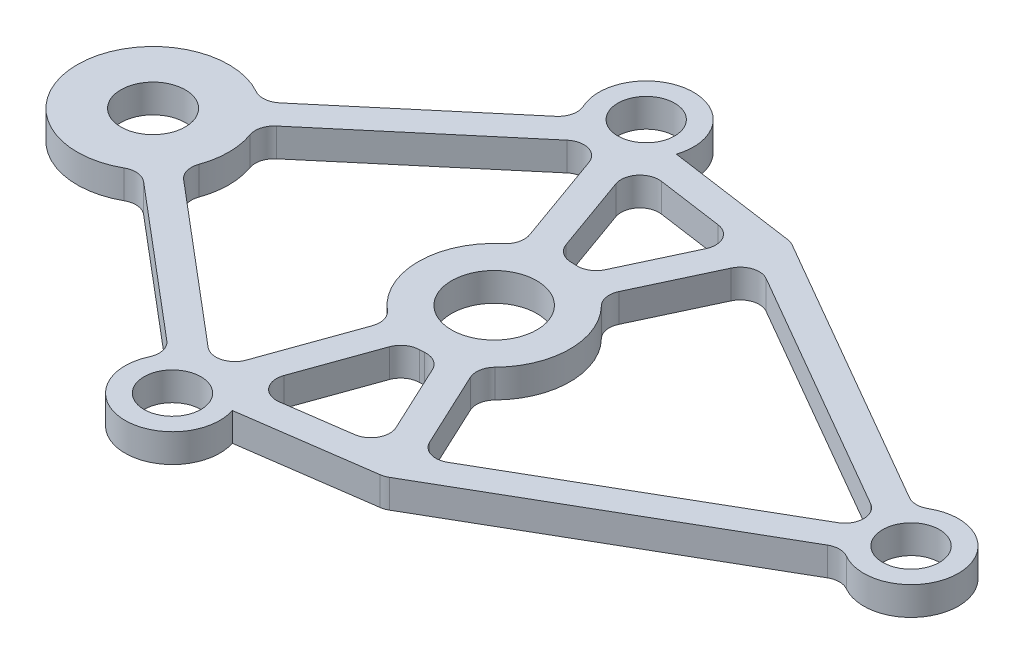
from build123d import *

# Parameters (mm, degrees)
SKETCH_1_R      = 2.25
SKETCH_1_R_2    = 1.7
SKETCH_1_R_3    = 1.5
EXTRUDE_1_DEPTH = 1.5


with BuildPart() as part:
    # 草图1 → 凸台-拉伸1 (new body)
    with BuildSketch(Plane(origin=(0, 0, 0), x_dir=(1, 0, 0), z_dir=(0, 1, 0))):
        with BuildLine():
            Line((19.75, 2.165063509), (5.096488448, 10.625272348))
            ThreePointArc((5.096488448, 10.625272348), (4.922427124, 10.704637858), (4.736437674, 10.749405626))
            Line((4.736437674, 10.749405626), (-2.101908222, 11.7159388))
            ThreePointArc((-2.101908222, 11.7159388), (-4.61878361, 14.995906411), (-6.744553684, 11.449929699))
            ThreePointArc((-6.744553684, 11.449929699), (-6.675732942, 10.813623622), (-7.006838923, 10.265909693))
            Line((-7.006838923, 10.265909693), (-14.905573539, 3.595069524))
            ThreePointArc((-14.905573539, 3.595069524), (-15.456234647, 3.363542696), (-16.040639512, 3.487249128))
            ThreePointArc((-16.040639512, 3.487249128), (-22, 0), (-16.040639512, -3.487249128))
            ThreePointArc((-16.040639512, -3.487249128), (-15.456234647, -3.363542696), (-14.905573539, -3.595069524))
            Line((-14.905573539, -3.595069524), (-7.006838923, -10.265909693))
            ThreePointArc((-7.006838923, -10.265909693), (-6.675732942, -10.813623622), (-6.744553684, -11.449929699))
            ThreePointArc((-6.744553684, -11.449929699), (-4.61878361, -14.995906411), (-2.101908222, -11.7159388))
            Line((-2.101908222, -11.7159388), (4.736437674, -10.749405626))
            ThreePointArc((4.736437674, -10.749405626), (4.922427124, -10.704637858), (5.096488448, -10.625272348))
            Line((5.096488448, -10.625272348), (19.75, -2.165063509))
            ThreePointArc((19.75, -2.165063509), (20.25, -2.031088913), (20.75, -2.165063509))
            ThreePointArc((20.75, -2.165063509), (24.5, 0), (20.75, 2.165063509))
            ThreePointArc((20.75, 2.165063509), (20.25, 2.031088913), (19.75, 2.165063509))
        make_face()
        Circle(SKETCH_1_R, mode=Mode.SUBTRACT)
        with Locations((-18, 0)):
            Circle(SKETCH_1_R_2, mode=Mode.SUBTRACT)
        with Locations((22, 0)):
            Circle(SKETCH_1_R_3, mode=Mode.SUBTRACT)
        with Locations((-4.47577596, 12.5)):
            Circle(SKETCH_1_R_3, mode=Mode.SUBTRACT)
        with Locations((-4.47577596, -12.5)):
            Circle(SKETCH_1_R_3, mode=Mode.SUBTRACT)
        with BuildLine():
            Line((2.23143448, 9.588554578), (-1.256530939, 10.081544307))
            ThreePointArc((-1.256530939, 10.081544307), (-2.171731289, 9.72303877), (-2.33794765, 8.754281823))
            Line((-2.33794765, 8.754281823), (-0.872808817, 4.662424773))
            ThreePointArc((-0.872808817, 4.662424773), (-0.512657064, 4.185850496), (0.054926934, 3.999622861))
            ThreePointArc((0.054926934, 3.999622861), (0.187612888, 3.995597753), (0.320092213, 3.987172052))
            ThreePointArc((0.320092213, 3.987172052), (0.902629068, 4.119395878), (1.305852753, 4.56012594))
            Line((1.305852753, 4.56012594), (2.997222742, 8.174556771))
            ThreePointArc((2.997222742, 8.174556771), (2.970810351, 9.074617878), (2.23143448, 9.588554578))
        make_face(mode=Mode.SUBTRACT)
        with BuildLine():
            Line((19, 0.866025404), (5.956182941, 8.396876694))
            ThreePointArc((5.956182941, 8.396876694), (5.156119776, 8.484770625), (4.550445454, 7.954690416))
            Line((4.550445454, 7.954690416), (2.664458984, 3.924367251))
            ThreePointArc((2.664458984, 3.924367251), (2.584431714, 3.332397688), (2.856157177, 2.800422501))
            ThreePointArc((2.856157177, 2.800422501), (4, 0), (2.856157177, -2.800422501))
            ThreePointArc((2.856157177, -2.800422501), (2.584431714, -3.332397688), (2.664458984, -3.924367251))
            Line((2.664458984, -3.924367251), (4.550445454, -7.954690416))
            ThreePointArc((4.550445454, -7.954690416), (5.156119776, -8.484770625), (5.956182941, -8.396876694))
            Line((5.956182941, -8.396876694), (19, -0.866025404))
            ThreePointArc((19, -0.866025404), (19.5, 0), (19, 0.866025404))
        make_face(mode=Mode.SUBTRACT)
        with BuildLine():
            Line((-2.33794765, -8.754281823), (-0.872808817, -4.662424773))
            ThreePointArc((-0.872808817, -4.662424773), (-0.512657064, -4.185850496), (0.054926934, -3.999622861))
            ThreePointArc((0.054926934, -3.999622861), (0.187612888, -3.995597753), (0.320092213, -3.987172052))
            ThreePointArc((0.320092213, -3.987172052), (0.902629068, -4.119395878), (1.305852753, -4.56012594))
            Line((1.305852753, -4.56012594), (2.997222742, -8.174556771))
            ThreePointArc((2.997222742, -8.174556771), (2.970810351, -9.074617878), (2.23143448, -9.588554578))
            Line((2.23143448, -9.588554578), (-1.256530939, -10.081544307))
            ThreePointArc((-1.256530939, -10.081544307), (-2.171731289, -9.72303877), (-2.33794765, -8.754281823))
        make_face(mode=Mode.SUBTRACT)
        with BuildLine():
            Line((-5.622052564, 9.472053038), (-13.937734763, 2.449081695))
            ThreePointArc((-13.937734763, 2.449081695), (-14.258158429, 1.944937864), (-14.23400713, 1.348071847))
            ThreePointArc((-14.23400713, 1.348071847), (-14, 0), (-14.23400713, -1.348071847))
            ThreePointArc((-14.23400713, -1.348071847), (-14.258158429, -1.944937864), (-13.937734763, -2.449081695))
            Line((-13.937734763, -2.449081695), (-5.622052564, -9.472053038))
            ThreePointArc((-5.622052564, -9.472053038), (-4.717022681, -9.673722513), (-4.035359228, -9.045164955))
            Line((-4.035359228, -9.045164955), (-2.285010045, -4.156769069))
            ThreePointArc((-2.285010045, -4.156769069), (-2.260804326, -3.559905256), (-2.581182025, -3.055732213))
            ThreePointArc((-2.581182025, -3.055732213), (-4, 0), (-2.581182025, 3.055732213))
            ThreePointArc((-2.581182025, 3.055732213), (-2.260804326, 3.559905256), (-2.285010045, 4.156769069))
            Line((-2.285010045, 4.156769069), (-4.035359228, 9.045164955))
            ThreePointArc((-4.035359228, 9.045164955), (-4.717022681, 9.673722513), (-5.622052564, 9.472053038))
        make_face(mode=Mode.SUBTRACT)
    extrude(amount=EXTRUDE_1_DEPTH)


solid = part.part
